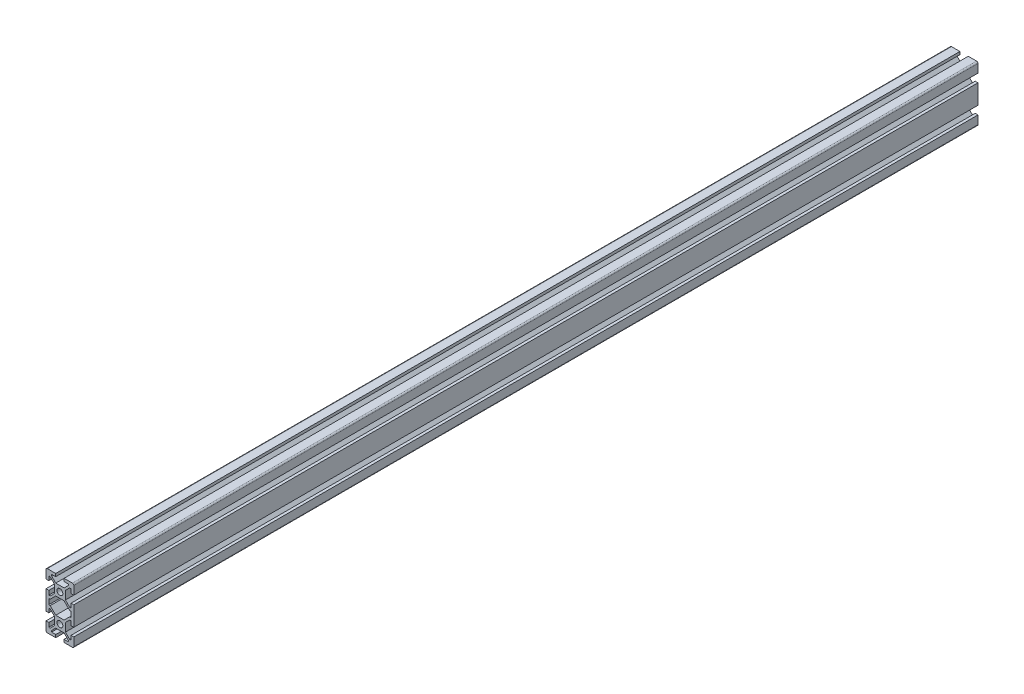
from build123d import *

# Parameters (mm, degrees)
SCHIZZO1_R                   = 2.1
ESTRUSIONE_ESTRUSIONE1_DEPTH = 650
RACCORDO1_R                  = 1


with BuildPart() as part:
    # Schizzo1 → Estrusione-Estrusione1 (new body)
    with BuildSketch(Plane.XY):
        Polygon((-3, 20), (-10, 20), (-10, 13), (-8, 13), (-8, 16), (-7, 16), (-4, 13), (-4, 7), (-7, 4), (-8, 4), (-8, 7), (-10, 7), (-10, -7), (-8, -7), (-8, -4), (-7, -4), (-4, -7), (-4, -13), (-7, -16), (-8, -16), (-8, -13), (-10, -13), (-10, -20), (-3, -20), (-3, -18), (-6, -18), (-6, -17), (-3, -14), (3, -14), (6, -17), (6, -18), (3, -18), (3, -20), (10, -20), (10, -13), (8, -13), (8, -16), (7, -16), (4, -13), (4, -7), (7, -4), (8, -4), (8, -7), (10, -7), (10, 7), (8, 7), (8, 4), (7, 4), (4, 7), (4, 13), (7, 16), (8, 16), (8, 13), (10, 13), (10, 20), (3, 20), (3, 18), (6, 18), (6, 17), (3, 14), (-3, 14), (-6, 17), (-6, 18), (-3, 18), align=None)
        Polygon((8, 2), (8, -2), (7, -2), (3, -6), (-3, -6), (-7, -2), (-8, -2), (-8, 2), (-7, 2), (-3, 6), (3, 6), (7, 2), align=None, mode=Mode.SUBTRACT)
        with Locations((0, 10)):
            Circle(SCHIZZO1_R, mode=Mode.SUBTRACT)
        with Locations((0, -10)):
            Circle(SCHIZZO1_R, mode=Mode.SUBTRACT)
    extrude(amount=ESTRUSIONE_ESTRUSIONE1_DEPTH)

    # Raccordo1
    raccordo1_edges = [part.edges().sort_by_distance(p)[0] for p in [
        (-10, 20, 325),
        (10, 20, 325),
        (10, -20, 325),
        (-10, -20, 325),
    ]]
    fillet(raccordo1_edges, radius=RACCORDO1_R)


solid = part.part
